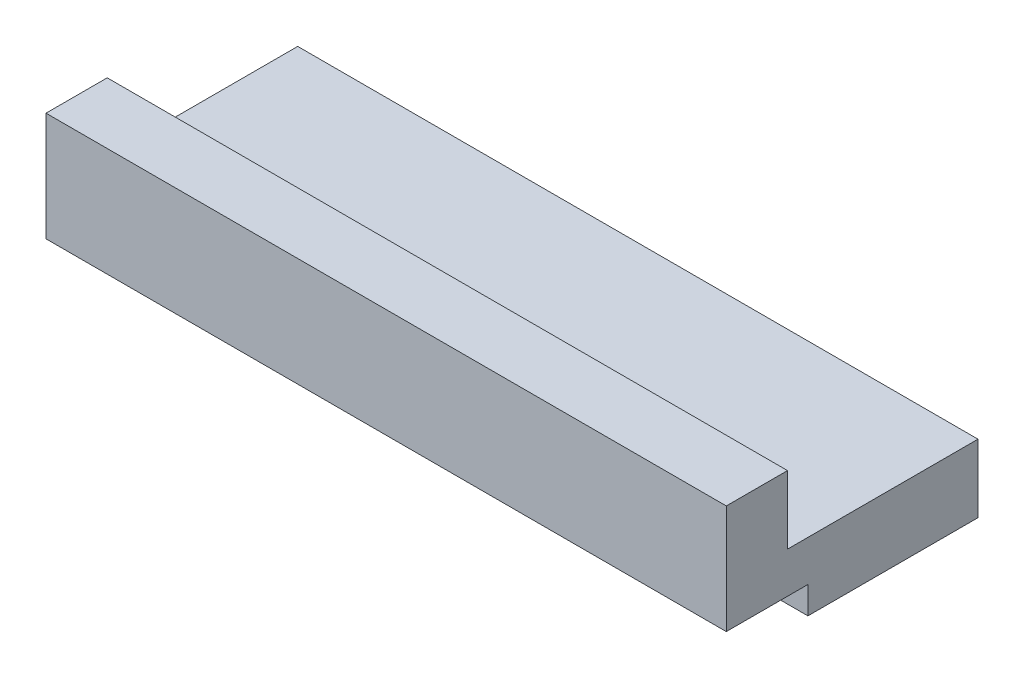
from build123d import *

# Parameters (mm, degrees)
SKETCH1_W           = 25.4
SKETCH1_H           = 2.286
BOSS_EXTRUDE1_DEPTH = 4.064
SKETCH3_W           = 25.4
SKETCH3_H           = 2.54
BOSS_EXTRUDE3_DEPTH = 7.112
SKETCH4_W           = 0.762
SKETCH4_H           = 1.016
CUT_EXTRUDE1_DEPTH  = 30.734


with BuildPart() as part:
    # Sketch1 → Boss-Extrude1 (new body)
    with BuildSketch(Plane(origin=(0, 0, 0), x_dir=(1, 0, 0), z_dir=(0, 1, 0))):
        with Locations((-2.386060606, 1.550939394)):
            Rectangle(SKETCH1_W, SKETCH1_H)
    extrude(amount=BOSS_EXTRUDE1_DEPTH)

    # Sketch3 → Boss-Extrude3 (add)
    with BuildSketch(Plane(origin=(0, 0, -2.693939394), x_dir=(-1, 0, 0), z_dir=(0, 0, -1))):
        with Locations((2.386060606, 0.254)):
            Rectangle(SKETCH3_W, SKETCH3_H)
    extrude(amount=BOSS_EXTRUDE3_DEPTH)

    # Sketch4 → Cut-Extrude1 (cut)
    with BuildSketch(Plane.ZY.offset(15.086060606)):
        with Locations((-3.074939394, -0.508)):
            Rectangle(SKETCH4_W, SKETCH4_H)
    extrude(amount=-CUT_EXTRUDE1_DEPTH, mode=Mode.SUBTRACT)


solid = part.part
